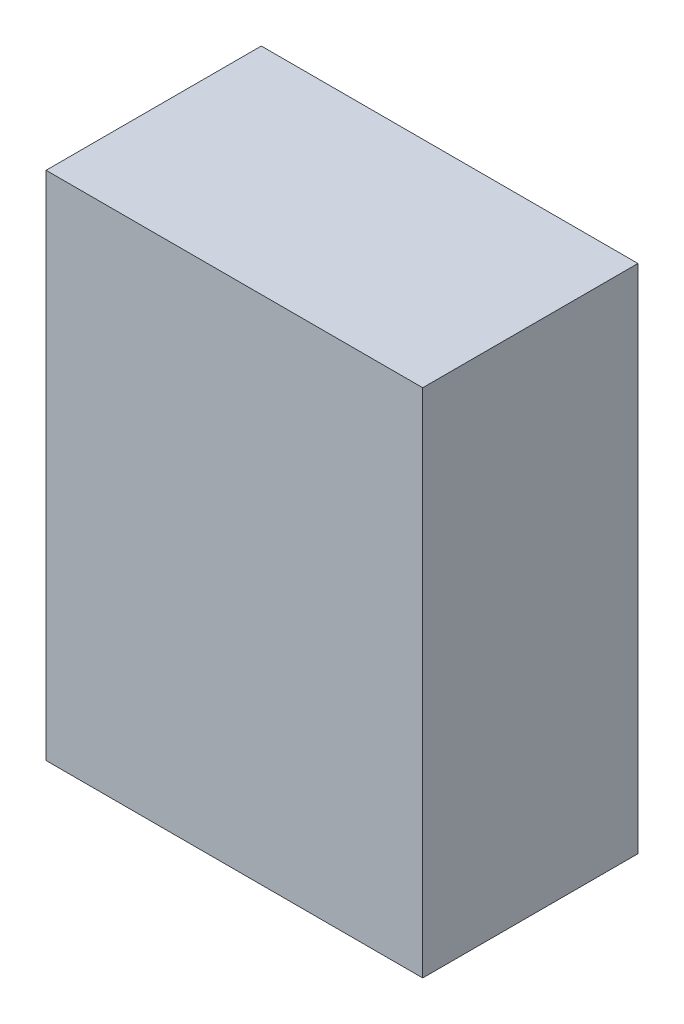
from build123d import *

# Parameters (mm, degrees)
ESQUISSE1_W        = 70
ESQUISSE1_H        = 95
BOSS_EXTRU_1_DEPTH = 40


with BuildPart() as part:
    # Esquisse1 → Boss.-Extru.1 (new body)
    with BuildSketch(Plane.XY):
        with Locations((-115.968992248, -0.368217054)):
            Rectangle(ESQUISSE1_W, ESQUISSE1_H)
    extrude(amount=BOSS_EXTRU_1_DEPTH)


solid = part.part
